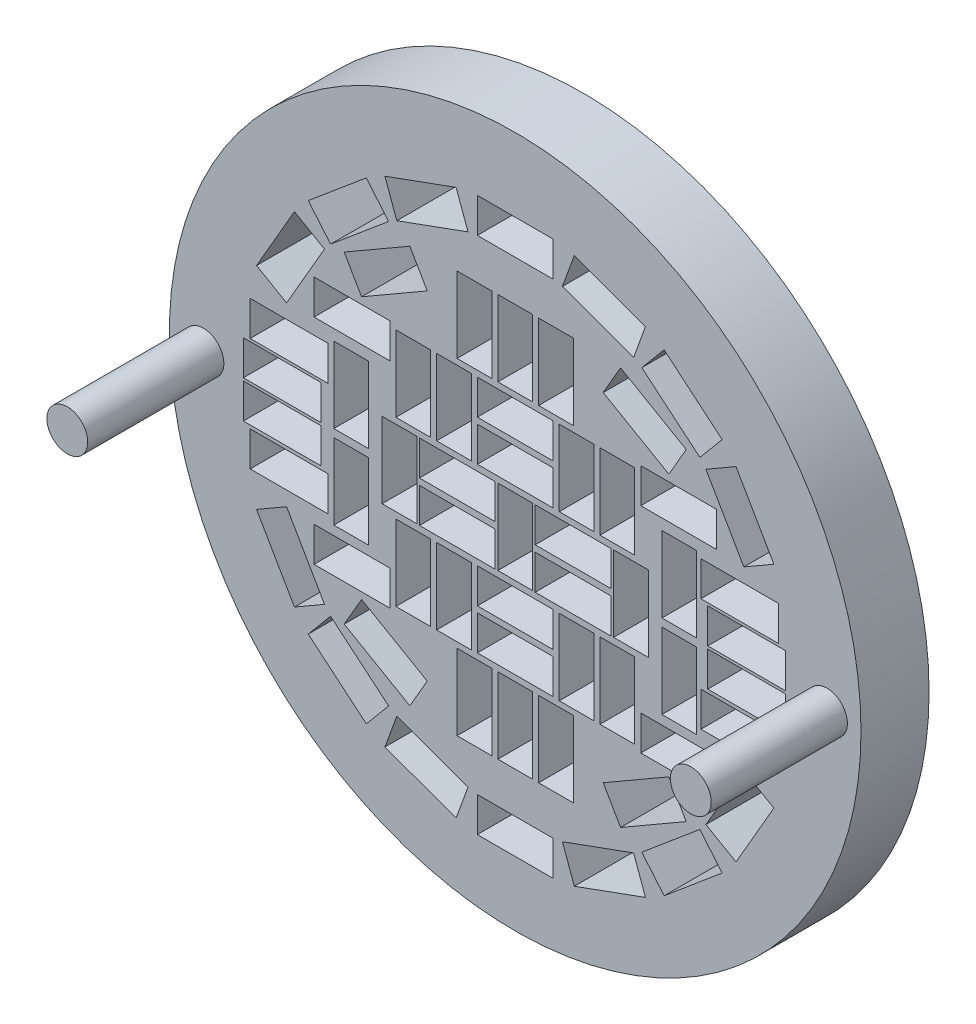
from build123d import *

# Parameters (mm, degrees)
ESQUISSE1_R             = 25.4
BOSS_EXTRU_1_DEPTH      = 5
ESQUISSE2_W             = 5.565
ESQUISSE2_H             = 2.55
ESQUISSE2_W_2           = 2.55
ESQUISSE2_H_2           = 5.565
ENL_V_MAT_EXTRU_1_DEPTH = 6
ESQUISSE3_W             = 5.7
ESQUISSE3_H             = 2.55
ENL_V_MAT_EXTRU_2_DEPTH = 6
ESQUISSE4_W             = 5.57
ESQUISSE4_H             = 2.55
ENL_V_MAT_EXTRU_3_DEPTH = 6
ESQUISSE5_R             = 1.5
BOSS_EXTRU_2_DEPTH      = 10


with BuildPart() as part:
    # Esquisse1 → Boss.-Extru.1 (new body)
    with BuildSketch(Plane.XY):
        with Locations((16.625210007, 7.108710486)):
            Circle(ESQUISSE1_R)
    extrude(amount=BOSS_EXTRU_1_DEPTH)

    # Esquisse2 → Enlèv. mat.-Extru.1 (cut, through all)
    with BuildSketch(Plane.XY.offset(5)):
        with Locations((12.372710007, 8.28394281)):
            Rectangle(ESQUISSE2_W, ESQUISSE2_H)
        with Locations((25.125210007, 6.784746769)):
            Rectangle(ESQUISSE2_W_2, ESQUISSE2_H_2)
        with Locations((16.625210007, 6.784746769)):
            Rectangle(ESQUISSE2_W_2, ESQUISSE2_H_2)
        with Locations((16.625210007, 18.784746769)):
            Rectangle(ESQUISSE2_W_2, ESQUISSE2_H_2)
        with Locations((8.125210007, 6.784746769)):
            Rectangle(ESQUISSE2_W_2, ESQUISSE2_H_2)
        with Locations((16.625210007, -5.215253231)):
            Rectangle(ESQUISSE2_W_2, ESQUISSE2_H_2)
        with Locations((20.872710007, 8.28394281)):
            Rectangle(ESQUISSE2_W, ESQUISSE2_H)
        with Locations((12.372710007, 5.26394281)):
            Rectangle(ESQUISSE2_W, ESQUISSE2_H)
        with Locations((20.872710007, 5.26394281)):
            Rectangle(ESQUISSE2_W, ESQUISSE2_H)
        with Locations((16.625210007, 2.278246769)):
            Rectangle(ESQUISSE2_W, ESQUISSE2_H)
        with Locations((16.625210007, 11.285246769)):
            Rectangle(ESQUISSE2_W, ESQUISSE2_H)
        with Locations((16.625210007, 14.278246769)):
            Rectangle(ESQUISSE2_W, ESQUISSE2_H)
        with Locations((16.625210007, -0.714753231)):
            Rectangle(ESQUISSE2_W, ESQUISSE2_H)
        with Locations((12.124710007, 12.784746769)):
            Rectangle(ESQUISSE2_W_2, ESQUISSE2_H_2)
        with Locations((9.134710007, 12.784746769)):
            Rectangle(ESQUISSE2_W_2, ESQUISSE2_H_2)
        with Locations((21.134710007, 12.784746769)):
            Rectangle(ESQUISSE2_W_2, ESQUISSE2_H_2)
        with Locations((24.124710007, 12.784746769)):
            Rectangle(ESQUISSE2_W_2, ESQUISSE2_H_2)
        with Locations((21.134710007, 0.754746769)):
            Rectangle(ESQUISSE2_W_2, ESQUISSE2_H_2)
        with Locations((24.124710007, 0.754746769)):
            Rectangle(ESQUISSE2_W_2, ESQUISSE2_H_2)
        with Locations((9.134710007, 0.754746769)):
            Rectangle(ESQUISSE2_W_2, ESQUISSE2_H_2)
        with Locations((12.124710007, 0.754746769)):
            Rectangle(ESQUISSE2_W_2, ESQUISSE2_H_2)
        Polygon((25.321877923, 22.543159749), (26.194029289, 24.939375932), (20.964639854, 26.84271803), (20.092488489, 24.446501847), align=None)
        with Locations((16.625210007, 25.842246769)):
            Rectangle(ESQUISSE2_W, ESQUISSE2_H)
        Polygon((30.18709934, 18.618375555), (31.826207744, 20.571788884), (27.563170418, 24.148901932), (25.924062014, 22.195488602), align=None)
        Polygon((33.41655675, 13.266281083), (35.62492153, 14.541281083), (32.84242153, 19.360712455), (30.63405675, 18.085712455), align=None)
        Polygon((30.63405675, -4.516218917), (32.84242153, -5.791218917), (35.62492153, -0.971787545), (33.41655675, 0.303212455), align=None)
        Polygon((25.924062014, -8.625995065), (27.563170418, -10.579408395), (31.826207744, -7.002295347), (30.18709934, -5.048882017), align=None)
        Polygon((20.092488489, -10.877008309), (20.964639854, -13.273224492), (26.194029289, -11.369882395), (25.321877923, -8.973666212), align=None)
        with Locations((16.625210007, -12.272753231)):
            Rectangle(ESQUISSE2_W, ESQUISSE2_H)
        Polygon((7.928542091, -8.973666212), (7.056390726, -11.369882395), (12.285780161, -13.273224492), (13.157931526, -10.877008309), align=None)
        Polygon((3.063320675, -5.048882017), (1.424212271, -7.002295347), (5.687249596, -10.579408395), (7.326358001, -8.625995065), align=None)
        Polygon((-0.166136735, 0.303212455), (-2.374501515, -0.971787545), (0.407998485, -5.791218917), (2.616363265, -4.516218917), align=None)
        Polygon((2.616363265, 18.085712455), (0.407998485, 19.360712455), (-2.374501515, 14.541281083), (-0.166136735, 13.266281083), align=None)
        Polygon((7.326358001, 22.195488602), (5.687249596, 24.148901932), (1.424212271, 20.571788884), (3.063320675, 18.618375555), align=None)
        with Locations((13.628210007, 18.778746769)):
            Rectangle(ESQUISSE2_W_2, ESQUISSE2_H_2)
        with Locations((19.618210007, 18.778746769)):
            Rectangle(ESQUISSE2_W_2, ESQUISSE2_H_2)
        with Locations((13.628210007, -5.221253231)):
            Rectangle(ESQUISSE2_W_2, ESQUISSE2_H_2)
        with Locations((19.618210007, -5.221253231)):
            Rectangle(ESQUISSE2_W_2, ESQUISSE2_H_2)
        with Locations((4.575210007, 9.79144281)):
            Rectangle(ESQUISSE2_W_2, ESQUISSE2_H_2)
        with Locations((28.675210007, 9.79144281)):
            Rectangle(ESQUISSE2_W_2, ESQUISSE2_H_2)
        with Locations((4.575210007, 3.65144281)):
            Rectangle(ESQUISSE2_W_2, ESQUISSE2_H_2)
        with Locations((28.675210007, 3.65144281)):
            Rectangle(ESQUISSE2_W_2, ESQUISSE2_H_2)
        Polygon((13.157931526, 24.446501847), (12.285780161, 26.84271803), (7.056390726, 24.939375932), (7.928542091, 22.543159749), align=None)
    extrude(amount=-ENL_V_MAT_EXTRU_1_DEPTH, mode=Mode.SUBTRACT)

    # Esquisse3 → Enlèv. mat.-Extru.2 (cut, through all)
    with BuildSketch(Plane.XY.offset(5)):
        with Locations((0.007210007, 10.942246769)):
            Rectangle(ESQUISSE3_W, ESQUISSE3_H)
        with Locations((33.117210007, 10.942246769)):
            Rectangle(ESQUISSE3_W, ESQUISSE3_H)
        with Locations((33.117210007, 2.642246769)):
            Rectangle(ESQUISSE3_W, ESQUISSE3_H)
        with Locations((0.007210007, 2.642246769)):
            Rectangle(ESQUISSE3_W, ESQUISSE3_H)
        with Locations((33.617210007, 8.192246769)):
            Rectangle(ESQUISSE3_W, ESQUISSE3_H)
        with Locations((-0.492789993, 8.192246769)):
            Rectangle(ESQUISSE3_W, ESQUISSE3_H)
        with Locations((33.617210007, 5.442246769)):
            Rectangle(ESQUISSE3_W, ESQUISSE3_H)
        with Locations((-0.492789993, 5.442246769)):
            Rectangle(ESQUISSE3_W, ESQUISSE3_H)
    extrude(amount=-ENL_V_MAT_EXTRU_2_DEPTH, mode=Mode.SUBTRACT)

    # Esquisse4 → Enlèv. mat.-Extru.3 (cut, through all)
    with BuildSketch(Plane.XY.offset(5)):
        with Locations((28.631710007, 14.64894281)):
            Rectangle(ESQUISSE4_W, ESQUISSE4_H)
        with Locations((4.631710007, 14.64894281)):
            Rectangle(ESQUISSE4_W, ESQUISSE4_H)
        with Locations((28.631710007, -1.08105719)):
            Rectangle(ESQUISSE4_W, ESQUISSE4_H)
        with Locations((4.631710007, -1.08105719)):
            Rectangle(ESQUISSE4_W, ESQUISSE4_H)
        Polygon((4.063320675, 18.618375555), (8.887082174, 21.403375555), (10.162082174, 19.195010775), (5.338320675, 16.410010775), align=None)
        Polygon((29.18709934, 18.618375555), (24.363337841, 21.403375555), (23.088337841, 19.195010775), (27.91209934, 16.410010775), align=None)
        Polygon((4.063320675, -5.048882017), (8.887082174, -7.833882017), (10.162082174, -5.625517237), (5.338320675, -2.840517237), align=None)
        Polygon((29.18709934, -5.048882017), (24.363337841, -7.833882017), (23.088337841, -5.625517237), (27.91209934, -2.840517237), align=None)
    extrude(amount=-ENL_V_MAT_EXTRU_3_DEPTH, mode=Mode.SUBTRACT)

    # Esquisse5 → Boss.-Extru.2 (add)
    with BuildSketch(Plane.XY.offset(5)):
        with Locations((-6.274789993, 7.108710486)):
            Circle(ESQUISSE5_R)
        with Locations((39.525210007, 7.108710486)):
            Circle(ESQUISSE5_R)
    extrude(amount=BOSS_EXTRU_2_DEPTH)


solid = part.part
